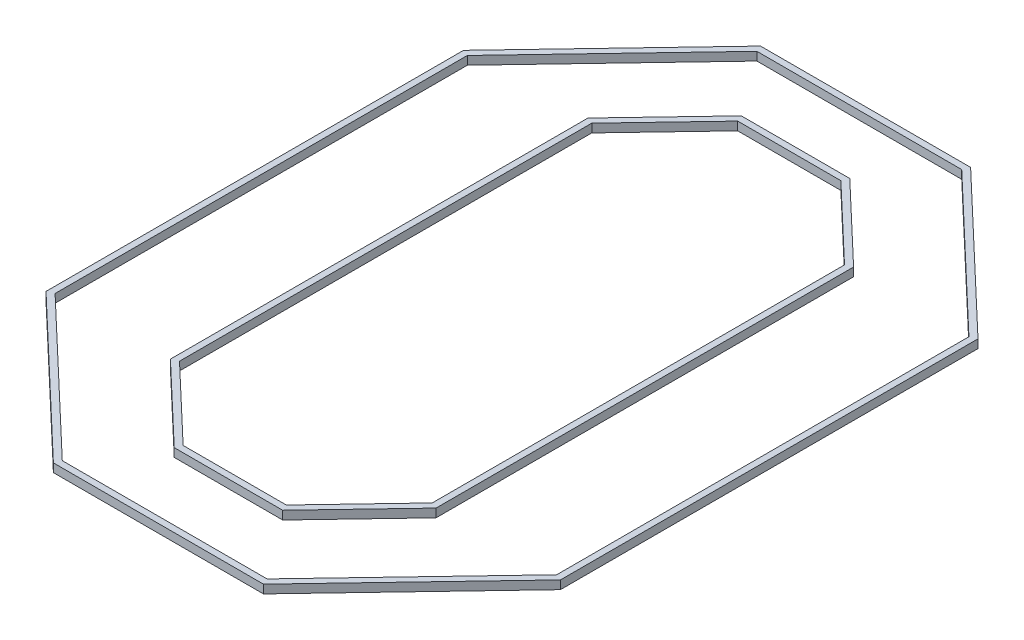
from build123d import *

# Parameters (mm, degrees)
BOSS_EXTRUDE1_DEPTH   = 101.6
BOSS_EXTRUDE1_2_DEPTH = 101.6


with BuildPart() as part:
    # Sketch1 → Boss-Extrude1 (new body)
    with BuildSketch(Plane(origin=(0, 0, 0), x_dir=(1, 0, 0), z_dir=(0, 1, 0))):
        Polygon((-2998.469529978, -2593.170550375), (-2998.469529978, -87.630470022), (-2998.469529978, 2416.798253617), (-1260.940080353, 4243.069529978), (1259.828723639, 4243.069529978), (3086.1, 2505.540080353), (3086.1, 0), (3086.1, -2504.428723639), (1348.570550375, -4330.7), (-1172.198253617, -4330.7), align=None)
        Polygon((-1141.740806339, -4254.5), (-2922.269529978, -2560.49038967), (-2922.269529978, -87.630470022), (-2922.269529978, 2386.340806339), (-1228.259919647, 4166.869529978), (1229.371276361, 4166.869529978), (3009.9, 2472.859919647), (3009.9, 0), (3009.9, -2473.971276361), (1315.89038967, -4254.5), align=None, mode=Mode.SUBTRACT)
    extrude(amount=BOSS_EXTRUDE1_DEPTH)


with BuildPart() as body_2:
    # Sketch1 → Boss-Extrude1 2 (new body)
    with BuildSketch(Plane(origin=(0, 0, 0), x_dir=(1, 0, 0), z_dir=(0, 1, 0))):
        Polygon((-651.340080353, 3402.692617336), (-1548.492617336, 2459.719300158), (-1548.492617336, -44.709423481), (-1548.492617336, -2550.249503833), (-605.519300158, -3447.402040816), (696.049503833, -3447.402040816), (1593.202040816, -2504.428723639), (1593.202040816, 0), (1593.202040816, 2505.540080353), (650.228723639, 3402.692617336), align=None)
        Polygon((-1472.292617336, 2429.26185288), (-1472.292617336, -44.709423481), (-1472.292617336, -2517.569343128), (-575.06185288, -3371.202040816), (663.369343128, -3371.202040816), (1517.002040816, -2473.971276361), (1517.002040816, 0), (1517.002040816, 2472.859919647), (619.771276361, 3326.492617336), (-618.659919647, 3326.492617336), align=None, mode=Mode.SUBTRACT)
    extrude(amount=BOSS_EXTRUDE1_2_DEPTH)


solid = Compound([part.part, body_2.part])
